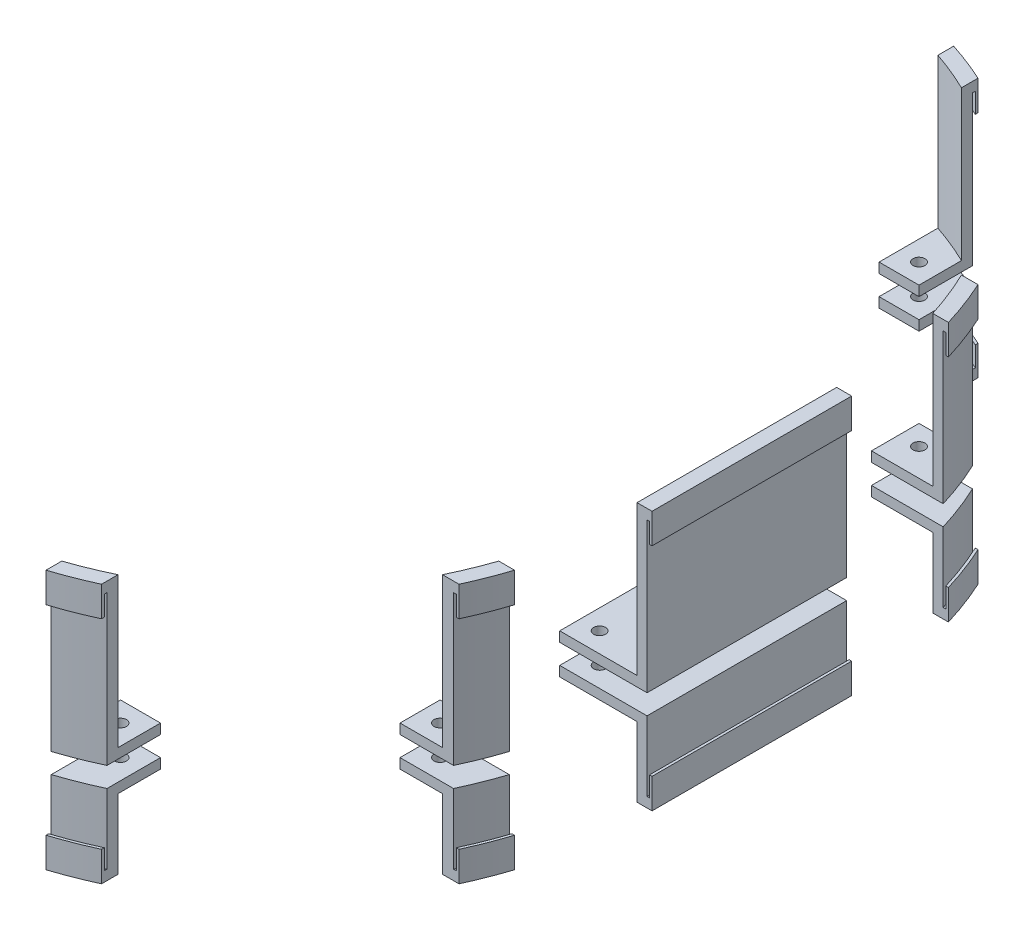
from build123d import *

# Parameters (mm, degrees)
BOSS_EXTRUDE1_DEPTH   = 6.35
CUT_EXTRUDE1_DEPTH    = 6.35
M4_CLEARANCE_HOLE1_D  = 4.5
F_6_CLEARANCE_HOLE1_D = 3.7973
F_6_CLEARANCE_HOLE2_D = 3.7973
SKETCH17_R            = 1.89865
SKETCH17_W            = 27.78125
SKETCH17_H            = 63.5
BOSS_EXTRUDE2_DEPTH   = 3.175
CUT_EXTRUDE4_DEPTH    = 6.35
SKETCH19_W            = 3.175
SKETCH19_H            = 63.5
BOSS_EXTRUDE3_DEPTH   = 44.45
SKETCH22_W            = 3.175
SKETCH22_H            = 63.5
BOSS_EXTRUDE4_DEPTH   = 19.05
SKETCH23_W            = 1.5875
SKETCH23_H            = 63.5
SKETCH23_W_2          = 3.175
BOSS_EXTRUDE5_DEPTH   = 3.175
SKETCH24_W            = 1.5875
SKETCH24_H            = 63.5
SKETCH24_W_2          = 3.175
BOSS_EXTRUDE6_DEPTH   = 3.175
SKETCH25_W            = 0.79375
SKETCH25_H            = 63.5
BOSS_EXTRUDE8_DEPTH   = 6.35
SKETCH27_W            = 0.79375
SKETCH27_H            = 63.5
BOSS_EXTRUDE9_DEPTH   = 6.35


with BuildPart() as part:
    # Sketch1 → Boss-Extrude1 (new body)
    with BuildSketch(Plane(origin=(0, 0, 0), x_dir=(1, 0, 0), z_dir=(0, 1, 0))):
        with BuildLine():
            Line((-34.13125, -148.43125), (34.13125, -148.43125))
            ThreePointArc((34.13125, -148.43125), (114.95355509, -114.95355509), (148.43125, -34.13125))
            Line((148.43125, -34.13125), (148.43125, 34.13125))
            ThreePointArc((148.43125, 34.13125), (114.95355509, 114.95355509), (34.13125, 148.43125))
            Line((34.13125, 148.43125), (-34.13125, 148.43125))
            ThreePointArc((-34.13125, 148.43125), (-114.95355509, 114.95355509), (-148.43125, 34.13125))
            Line((-148.43125, 34.13125), (-148.43125, -34.13125))
            ThreePointArc((-148.43125, -34.13125), (-114.95355509, -114.95355509), (-34.13125, -148.43125))
        make_face()
    extrude(amount=BOSS_EXTRUDE1_DEPTH)

    # Sketch4 → Cut-Extrude1 (cut)
    with BuildSketch(Plane(origin=(0, 6.35, 0), x_dir=(1, 0, 0), z_dir=(0, 1, 0))):
        with BuildLine():
            Line((-39.448, 120.290181937), (39.448, 120.290181937))
            ThreePointArc((39.448, 120.290181937), (49.454528647, 121.702619905), (58.679163809, 125.829568258))
            ThreePointArc((58.679163809, 125.829568258), (62.23, 132.253581937), (58.679163809, 138.677595616))
            ThreePointArc((58.679163809, 138.677595616), (49.454528647, 142.804543969), (39.448, 144.216981937))
            Line((39.448, 144.216981937), (-39.448, 144.216981937))
            ThreePointArc((-39.448, 144.216981937), (-49.454528647, 142.804543969), (-58.679163809, 138.677595616))
            ThreePointArc((-58.679163809, 138.677595616), (-62.23, 132.253581937), (-58.679163809, 125.829568258))
            ThreePointArc((-58.679163809, 125.829568258), (-49.454528647, 121.702619905), (-39.448, 120.290181937))
        make_face()
        with BuildLine():
            ThreePointArc((-39.448, 145.804481937), (-49.893930566, 144.330021666), (-59.523633513, 140.021852723))
            ThreePointArc((-59.523633513, 140.021852723), (-63.8175, 132.253581937), (-59.523633513, 124.485311151))
            ThreePointArc((-59.523633513, 124.485311151), (-49.893930566, 120.177142208), (-39.448, 118.702681937))
            Line((-39.448, 118.702681937), (39.448, 118.702681937))
            ThreePointArc((39.448, 118.702681937), (49.893930566, 120.177142208), (59.523633513, 124.485311151))
            ThreePointArc((59.523633513, 124.485311151), (63.8175, 132.253581937), (59.523633513, 140.021852723))
            ThreePointArc((59.523633513, 140.021852723), (49.893930566, 144.330021666), (39.448, 145.804481937))
            Line((39.448, 145.804481937), (-39.448, 145.804481937))
        make_face()
        with BuildLine():
            ThreePointArc((39.448, 120.290181937), (49.454528647, 121.702619905), (58.679163809, 125.829568258))
            ThreePointArc((58.679163809, 125.829568258), (62.23, 132.253581937), (58.679163809, 138.677595616))
            ThreePointArc((58.679163809, 138.677595616), (49.454528647, 142.804543969), (39.448, 144.216981937))
            Line((39.448, 144.216981937), (-39.448, 144.216981937))
            ThreePointArc((-39.448, 144.216981937), (-49.454528647, 142.804543969), (-58.679163809, 138.677595616))
            ThreePointArc((-58.679163809, 138.677595616), (-62.23, 132.253581937), (-58.679163809, 125.829568258))
            ThreePointArc((-58.679163809, 125.829568258), (-49.454528647, 121.702619905), (-39.448, 120.290181937))
            Line((-39.448, 120.290181937), (39.448, 120.290181937))
        make_face(mode=Mode.SUBTRACT)
        with BuildLine():
            ThreePointArc((-58.679163809, -125.829568258), (-62.23, -132.253581937), (-58.679163809, -138.677595616))
            ThreePointArc((-58.679163809, -138.677595616), (-49.454528647, -142.804543969), (-39.448, -144.216981937))
            Line((-39.448, -144.216981937), (39.448, -144.216981937))
            ThreePointArc((39.448, -144.216981937), (49.454528647, -142.804543969), (58.679163809, -138.677595616))
            ThreePointArc((58.679163809, -138.677595616), (62.23, -132.253581937), (58.679163809, -125.829568258))
            ThreePointArc((58.679163809, -125.829568258), (49.454528647, -121.702619905), (39.448, -120.290181937))
            Line((39.448, -120.290181937), (-39.448, -120.290181937))
            ThreePointArc((-39.448, -120.290181937), (-49.454528647, -121.702619905), (-58.679163809, -125.829568258))
        make_face()
        with BuildLine():
            ThreePointArc((-59.523633513, -124.485311151), (-63.8175, -132.253581937), (-59.523633513, -140.021852723))
            ThreePointArc((-59.523633513, -140.021852723), (-49.893930566, -144.330021666), (-39.448, -145.804481937))
            Line((-39.448, -145.804481937), (39.448, -145.804481937))
            ThreePointArc((39.448, -145.804481937), (49.893930566, -144.330021666), (59.523633513, -140.021852723))
            ThreePointArc((59.523633513, -140.021852723), (63.8175, -132.253581937), (59.523633513, -124.485311151))
            ThreePointArc((59.523633513, -124.485311151), (49.893930566, -120.177142208), (39.448, -118.702681937))
            Line((39.448, -118.702681937), (-39.448, -118.702681937))
            ThreePointArc((-39.448, -118.702681937), (-49.893930566, -120.177142208), (-59.523633513, -124.485311151))
        make_face()
        with BuildLine():
            ThreePointArc((-58.679163809, -138.677595616), (-49.454528647, -142.804543969), (-39.448, -144.216981937))
            Line((-39.448, -144.216981937), (39.448, -144.216981937))
            ThreePointArc((39.448, -144.216981937), (49.454528647, -142.804543969), (58.679163809, -138.677595616))
            ThreePointArc((58.679163809, -138.677595616), (62.23, -132.253581937), (58.679163809, -125.829568258))
            ThreePointArc((58.679163809, -125.829568258), (49.454528647, -121.702619905), (39.448, -120.290181937))
            Line((39.448, -120.290181937), (-39.448, -120.290181937))
            ThreePointArc((-39.448, -120.290181937), (-49.454528647, -121.702619905), (-58.679163809, -125.829568258))
            ThreePointArc((-58.679163809, -125.829568258), (-62.23, -132.253581937), (-58.679163809, -138.677595616))
        make_face(mode=Mode.SUBTRACT)
    extrude(amount=-CUT_EXTRUDE1_DEPTH, mode=Mode.SUBTRACT)

    # M4 Clearance Hole1 (through all)
    with Locations(Plane(origin=(0, 6.35, 0), x_dir=(1, 0, 0), z_dir=(0, 1, 0))):
        with Locations((-16, -103.6875), (16, -103.6875), (22, -60.325), (-10, -60.325), (-10, 60.325), (22, 60.325), (16, 103.6875), (-16, 103.6875)):
            Hole(M4_CLEARANCE_HOLE1_D / 2)

    # #6 Clearance Hole1 (through all)
    with Locations(Plane(origin=(0, 6.35, 0), x_dir=(1, 0, 0), z_dir=(0, 1, 0))):
        with Locations((-101.6, -101.6), (-101.6, 101.6), (101.6, 101.6), (101.6, -101.6), (-127, -76.2), (-127, -50.8), (-127, 50.8), (-127, 76.2), (-101.6, 76.2), (-101.6, 50.8), (-101.6, 25.4), (-101.6, 0), (-101.6, -25.4), (-101.6, -50.8), (-101.6, -76.2), (-76.2, -101.6), (-50.8, -101.6), (-50.8, -76.2), (-76.2, -76.2), (-76.2, -50.8), (-50.8, -50.8), (-50.8, -25.4), (-76.2, -25.4), (-76.2, 0), (-50.8, 0), (-50.8, 25.4), (-76.2, 25.4), (-76.2, 50.8), (-50.8, 50.8), (-50.8, 76.2), (-76.2, 76.2), (-76.2, 101.6), (-50.8, 101.6), (50.8, -101.6), (76.2, -101.6), (101.6, -76.2), (127, -76.2), (127, -50.8), (101.6, -25.4), (101.6, -50.8), (76.2, -25.4), (76.2, -50.8), (76.2, -76.2), (50.8, -76.2), (50.8, -50.8), (50.8, -25.4), (50.8, 0), (76.2, 0), (101.6, 0), (101.6, 25.4), (101.6, 50.8), (101.6, 76.2), (127, 50.8), (127, 76.2), (76.2, 101.6), (50.8, 101.6), (50.8, 76.2), (76.2, 76.2), (76.2, 50.8), (76.2, 25.4), (50.8, 25.4), (50.8, 50.8), (0, 0), (-25.4, -25.4), (-25.4, 0), (-25.4, 25.4), (0, 25.4), (25.4, 25.4), (25.4, 0), (25.4, -25.4), (0, -25.4), (127, -25.4), (127, 0), (127, 25.4), (-127, -25.4), (-127, 0), (-127, 25.4)):
            Hole(F_6_CLEARANCE_HOLE1_D / 2)

    # #6 Clearance Hole2 (through all)
    with Locations(Plane(origin=(0, 6.35, 0), x_dir=(1, 0, 0), z_dir=(0, 1, 0))):
        with Locations((-76.2, -127), (76.2, -127), (76.2, 127), (-76.2, 127)):
            Hole(F_6_CLEARANCE_HOLE2_D / 2)

    # Sketch17 → Boss-Extrude2 (add)
    with BuildSketch(Plane(origin=(0, 6.35, 0), x_dir=(1, 0, 0), z_dir=(0, 1, 0))):
        with BuildLine():
            Line((69.85, -142.706849922), (69.85, -120.65))
            Line((69.85, -120.65), (82.55, -120.65))
            Line((82.55, -120.65), (82.55, -137.6692365))
            ThreePointArc((82.55, -137.6692365), (76.275337531, -140.377971767), (69.85, -142.706849922))
        make_face()
        with Locations((76.2, -127)):
            Circle(SKETCH17_R, mode=Mode.SUBTRACT)
        with BuildLine():
            Line((137.6692365, -82.55), (120.65, -82.55))
            Line((120.65, -82.55), (120.65, -69.85))
            Line((120.65, -69.85), (142.706849922, -69.85))
            ThreePointArc((142.706849922, -69.85), (140.377971767, -76.275337531), (137.6692365, -82.55))
        make_face()
        with Locations((127, -76.2)):
            Circle(SKETCH17_R, mode=Mode.SUBTRACT)
        with Locations((134.540625, 0)):
            Rectangle(SKETCH17_W, SKETCH17_H)
        with Locations((127, -25.4)):
            Circle(SKETCH17_R, mode=Mode.SUBTRACT)
        with Locations((127, 0)):
            Circle(SKETCH17_R, mode=Mode.SUBTRACT)
        with Locations((127, 25.4)):
            Circle(SKETCH17_R, mode=Mode.SUBTRACT)
        with BuildLine():
            Line((143.474597969, 67.425727845), (120.65, 67.425727845))
            Line((120.65, 67.425727845), (120.65, 82.55))
            Line((120.65, 82.55), (137.6692365, 82.55))
            ThreePointArc((137.6692365, 82.55), (140.840207184, 75.090845416), (143.474597969, 67.425727845))
        make_face()
        with Locations((127, 76.2)):
            Circle(SKETCH17_R, mode=Mode.SUBTRACT)
        with BuildLine():
            Line((82.55, 120.65), (82.55, 137.6692365))
            ThreePointArc((82.55, 137.6692365), (76.275337531, 140.377971767), (69.85, 142.706849922))
            Line((69.85, 142.706849922), (69.85, 120.65))
            Line((69.85, 120.65), (82.55, 120.65))
        make_face()
        with Locations((76.2, 127)):
            Circle(SKETCH17_R, mode=Mode.SUBTRACT)
    boss_extrude2 = extrude(amount=BOSS_EXTRUDE2_DEPTH)

    # Mirror3: Boss-Extrude2 across plane
    add(boss_extrude2.mirror(Plane.ZX.offset(3.175)))

    # Sketch18 → Cut-Extrude4 (cut)
    with BuildSketch(Plane.XZ):
        with BuildLine():
            Line((-148.43125, 34.13125), (-148.43125, -34.13125))
            ThreePointArc((-148.43125, -34.13125), (-114.95355509, -114.95355509), (-34.13125, -148.43125))
            Line((-34.13125, -148.43125), (34.13125, -148.43125))
            ThreePointArc((34.13125, -148.43125), (114.95355509, -114.95355509), (148.43125, -34.13125))
            Line((148.43125, -34.13125), (148.43125, 34.13125))
            ThreePointArc((148.43125, 34.13125), (114.95355509, 114.95355509), (34.13125, 148.43125))
            Line((34.13125, 148.43125), (-34.13125, 148.43125))
            ThreePointArc((-34.13125, 148.43125), (-114.95355509, 114.95355509), (-148.43125, 34.13125))
        make_face()
    extrude(amount=-CUT_EXTRUDE4_DEPTH, mode=Mode.SUBTRACT)

    # Sketch19 → Boss-Extrude3 (add)
    with BuildSketch(Plane(origin=(0, 9.525, 0), x_dir=(1, 0, 0), z_dir=(0, 1, 0))):
        with BuildLine():
            Line((82.55, 134.153198958), (82.55, 137.6692365))
            ThreePointArc((82.55, 137.6692365), (76.275337531, 140.377971767), (69.85, 142.706849922))
            Line((69.85, 142.706849922), (69.85, 139.35927157))
            ThreePointArc((69.85, 139.35927157), (76.280455503, 136.952503155), (82.55, 134.153198958))
        make_face()
        with Locations((146.84375, 0)):
            Rectangle(SKETCH19_W, SKETCH19_H)
        with BuildLine():
            Line((140.151264007, 67.425727845), (143.474597969, 67.425727845))
            ThreePointArc((143.474597969, 67.425727845), (140.840207184, 75.090845416), (137.6692365, 82.55))
            Line((137.6692365, 82.55), (134.153198958, 82.55))
            ThreePointArc((134.153198958, 82.55), (137.429403554, 75.097786311), (140.151264007, 67.425727845))
        make_face()
        with BuildLine():
            Line((134.153198958, -82.55), (137.6692365, -82.55))
            ThreePointArc((137.6692365, -82.55), (140.377971767, -76.275337531), (142.706849922, -69.85))
            Line((142.706849922, -69.85), (139.35927157, -69.85))
            ThreePointArc((139.35927157, -69.85), (136.952503155, -76.280455503), (134.153198958, -82.55))
        make_face()
        with BuildLine():
            Line((69.85, -139.35927157), (69.85, -142.706849922))
            ThreePointArc((69.85, -142.706849922), (76.275337531, -140.377971767), (82.55, -137.6692365))
            Line((82.55, -137.6692365), (82.55, -134.153198958))
            ThreePointArc((82.55, -134.153198958), (76.280455503, -136.952503155), (69.85, -139.35927157))
        make_face()
    extrude(amount=BOSS_EXTRUDE3_DEPTH)

    # Sketch22 → Boss-Extrude4 (add)
    with BuildSketch(Plane.XZ.offset(3.175)):
        with BuildLine():
            Line((137.6692365, 82.55), (134.153198958, 82.55))
            ThreePointArc((134.153198958, 82.55), (136.952503155, 76.280455503), (139.35927157, 69.85))
            Line((139.35927157, 69.85), (142.706849922, 69.85))
            ThreePointArc((142.706849922, 69.85), (140.377971767, 76.275337531), (137.6692365, 82.55))
        make_face()
        with BuildLine():
            Line((143.474597969, -67.425727845), (140.151264007, -67.425727845))
            ThreePointArc((140.151264007, -67.425727845), (137.429403554, -75.097786311), (134.153198958, -82.55))
            Line((134.153198958, -82.55), (137.6692365, -82.55))
            ThreePointArc((137.6692365, -82.55), (140.840207184, -75.090845416), (143.474597969, -67.425727845))
        make_face()
        with Locations((146.84375, 0)):
            Rectangle(SKETCH22_W, SKETCH22_H)
        with BuildLine():
            Line((82.55, -137.6692365), (82.55, -134.153198958))
            ThreePointArc((82.55, -134.153198958), (76.280455503, -136.952503155), (69.85, -139.35927157))
            Line((69.85, -139.35927157), (69.85, -142.706849922))
            ThreePointArc((69.85, -142.706849922), (76.275337531, -140.377971767), (82.55, -137.6692365))
        make_face()
        with BuildLine():
            Line((69.85, 142.706849922), (69.85, 139.35927157))
            ThreePointArc((69.85, 139.35927157), (76.280455503, 136.952503155), (82.55, 134.153198958))
            Line((82.55, 134.153198958), (82.55, 137.6692365))
            ThreePointArc((82.55, 137.6692365), (76.275337531, 140.377971767), (69.85, 142.706849922))
        make_face()
    extrude(amount=BOSS_EXTRUDE4_DEPTH)

    # Sketch23 → Boss-Extrude5 (add)
    with BuildSketch(Plane(origin=(0, 53.975, 0), x_dir=(1, 0, 0), z_dir=(0, 1, 0))):
        with BuildLine():
            Line((69.85, -142.706849922), (69.85, -144.376810249))
            ThreePointArc((69.85, -144.376810249), (76.272967802, -142.08488948), (82.55, -139.419128242))
            Line((82.55, -139.419128242), (82.55, -137.6692365))
            ThreePointArc((82.55, -137.6692365), (76.275337531, -140.377971767), (69.85, -142.706849922))
        make_face()
        with BuildLine():
            Line((82.55, -137.6692365), (82.55, -134.153198958))
            ThreePointArc((82.55, -134.153198958), (76.280455503, -136.952503155), (69.85, -139.35927157))
            Line((69.85, -139.35927157), (69.85, -142.706849922))
            ThreePointArc((69.85, -142.706849922), (76.275337531, -140.377971767), (82.55, -137.6692365))
        make_face()
        with BuildLine():
            Line((137.6692365, -82.55), (139.419128242, -82.55))
            ThreePointArc((139.419128242, -82.55), (142.08488948, -76.272967802), (144.376810249, -69.85))
            Line((144.376810249, -69.85), (142.706849922, -69.85))
            ThreePointArc((142.706849922, -69.85), (140.377971767, -76.275337531), (137.6692365, -82.55))
        make_face()
        with BuildLine():
            Line((134.153198958, -82.55), (137.6692365, -82.55))
            ThreePointArc((137.6692365, -82.55), (140.377971767, -76.275337531), (142.706849922, -69.85))
            Line((142.706849922, -69.85), (139.35927157, -69.85))
            ThreePointArc((139.35927157, -69.85), (136.952503155, -76.280455503), (134.153198958, -82.55))
        make_face()
        with Locations((149.225, 0)):
            Rectangle(SKETCH23_W, SKETCH23_H)
        with Locations((146.84375, 0)):
            Rectangle(SKETCH23_W_2, SKETCH23_H)
        with BuildLine():
            Line((143.474597969, 67.425727845), (145.13300855, 67.425727845))
            ThreePointArc((145.13300855, 67.425727845), (142.540141001, 75.087629335), (139.419128242, 82.55))
            Line((139.419128242, 82.55), (137.6692365, 82.55))
            ThreePointArc((137.6692365, 82.55), (140.840207184, 75.090845416), (143.474597969, 67.425727845))
        make_face()
        with BuildLine():
            Line((140.151264007, 67.425727845), (143.474597969, 67.425727845))
            ThreePointArc((143.474597969, 67.425727845), (140.840207184, 75.090845416), (137.6692365, 82.55))
            Line((137.6692365, 82.55), (134.153198958, 82.55))
            ThreePointArc((134.153198958, 82.55), (137.429403554, 75.097786311), (140.151264007, 67.425727845))
        make_face()
        with BuildLine():
            ThreePointArc((82.55, 134.153198958), (76.280455503, 136.952503155), (69.85, 139.35927157))
            Line((69.85, 139.35927157), (69.85, 142.706849922))
            ThreePointArc((69.85, 142.706849922), (76.275337531, 140.377971767), (82.55, 137.6692365))
            Line((82.55, 137.6692365), (82.55, 134.153198958))
        make_face()
        with BuildLine():
            Line((82.55, 137.6692365), (82.55, 139.419128242))
            ThreePointArc((82.55, 139.419128242), (76.272967802, 142.08488948), (69.85, 144.376810249))
            Line((69.85, 144.376810249), (69.85, 142.706849922))
            ThreePointArc((69.85, 142.706849922), (76.275337531, 140.377971767), (82.55, 137.6692365))
        make_face()
    extrude(amount=BOSS_EXTRUDE5_DEPTH)

    # Sketch24 → Boss-Extrude6 (add)
    with BuildSketch(Plane.XZ.offset(22.225)):
        with BuildLine():
            ThreePointArc((142.706849922, 69.85), (140.377971767, 76.275337531), (137.6692365, 82.55))
            Line((137.6692365, 82.55), (139.419128242, 82.55))
            ThreePointArc((139.419128242, 82.55), (142.08488948, 76.272967802), (144.376810249, 69.85))
            Line((144.376810249, 69.85), (142.706849922, 69.85))
        make_face()
        with BuildLine():
            Line((142.706849922, 69.85), (139.35927157, 69.85))
            ThreePointArc((139.35927157, 69.85), (136.952503155, 76.280455503), (134.153198958, 82.55))
            Line((134.153198958, 82.55), (137.6692365, 82.55))
            ThreePointArc((137.6692365, 82.55), (140.377971767, 76.275337531), (142.706849922, 69.85))
        make_face()
        with Locations((149.225, 0)):
            Rectangle(SKETCH24_W, SKETCH24_H)
        with Locations((146.84375, 0)):
            Rectangle(SKETCH24_W_2, SKETCH24_H)
        with BuildLine():
            ThreePointArc((137.6692365, -82.55), (140.840207184, -75.090845416), (143.474597969, -67.425727845))
            Line((143.474597969, -67.425727845), (145.13300855, -67.425727845))
            ThreePointArc((145.13300855, -67.425727845), (142.540141001, -75.087629335), (139.419128242, -82.55))
            Line((139.419128242, -82.55), (137.6692365, -82.55))
        make_face()
        with BuildLine():
            Line((137.6692365, -82.55), (134.153198958, -82.55))
            ThreePointArc((134.153198958, -82.55), (137.429403554, -75.097786311), (140.151264007, -67.425727845))
            Line((140.151264007, -67.425727845), (143.474597969, -67.425727845))
            ThreePointArc((143.474597969, -67.425727845), (140.840207184, -75.090845416), (137.6692365, -82.55))
        make_face()
        with BuildLine():
            ThreePointArc((82.55, 137.6692365), (76.275337531, 140.377971767), (69.85, 142.706849922))
            Line((69.85, 142.706849922), (69.85, 144.376810249))
            ThreePointArc((69.85, 144.376810249), (76.272967802, 142.08488948), (82.55, 139.419128242))
            Line((82.55, 139.419128242), (82.55, 137.6692365))
        make_face()
        with BuildLine():
            Line((82.55, 137.6692365), (82.55, 134.153198958))
            ThreePointArc((82.55, 134.153198958), (76.280455503, 136.952503155), (69.85, 139.35927157))
            Line((69.85, 139.35927157), (69.85, 142.706849922))
            ThreePointArc((69.85, 142.706849922), (76.275337531, 140.377971767), (82.55, 137.6692365))
        make_face()
        with BuildLine():
            Line((69.85, -142.706849922), (69.85, -139.35927157))
            ThreePointArc((69.85, -139.35927157), (76.280455503, -136.952503155), (82.55, -134.153198958))
            Line((82.55, -134.153198958), (82.55, -137.6692365))
            ThreePointArc((82.55, -137.6692365), (76.275337531, -140.377971767), (69.85, -142.706849922))
        make_face()
        with BuildLine():
            ThreePointArc((69.85, -142.706849922), (76.275337531, -140.377971767), (82.55, -137.6692365))
            Line((82.55, -137.6692365), (82.55, -139.419128242))
            ThreePointArc((82.55, -139.419128242), (76.272967802, -142.08488948), (69.85, -144.376810249))
            Line((69.85, -144.376810249), (69.85, -142.706849922))
        make_face()
    extrude(amount=BOSS_EXTRUDE6_DEPTH)

    # Sketch25 → Boss-Extrude8 (add)
    with BuildSketch(Plane.XZ.offset(-53.975)):
        with BuildLine():
            ThreePointArc((69.85, -144.376810249), (76.272967802, -142.08488948), (82.55, -139.419128242))
            Line((82.55, -139.419128242), (82.55, -138.544831193))
            ThreePointArc((82.55, -138.544831193), (76.274137808, -141.231895639), (69.85, -143.54213697))
            Line((69.85, -143.54213697), (69.85, -144.376810249))
        make_face()
        with BuildLine():
            ThreePointArc((144.304064406, -67.425727845), (141.690611266, -75.089217394), (138.544831193, -82.55))
            Line((138.544831193, -82.55), (139.419128242, -82.55))
            ThreePointArc((139.419128242, -82.55), (142.540141001, -75.087629335), (145.13300855, -67.425727845))
            Line((145.13300855, -67.425727845), (144.304064406, -67.425727845))
        make_face()
        with Locations((149.621875, 0)):
            Rectangle(SKETCH25_W, SKETCH25_H)
        with BuildLine():
            Line((139.419128242, 82.55), (138.544831193, 82.55))
            ThreePointArc((138.544831193, 82.55), (141.231895639, 76.274137808), (143.54213697, 69.85))
            Line((143.54213697, 69.85), (144.376810249, 69.85))
            ThreePointArc((144.376810249, 69.85), (142.08488948, 76.272967802), (139.419128242, 82.55))
        make_face()
        with BuildLine():
            Line((69.85, 144.376810249), (69.85, 143.54213697))
            ThreePointArc((69.85, 143.54213697), (76.274137808, 141.231895639), (82.55, 138.544831193))
            Line((82.55, 138.544831193), (82.55, 139.419128242))
            ThreePointArc((82.55, 139.419128242), (76.272967802, 142.08488948), (69.85, 144.376810249))
        make_face()
    extrude(amount=BOSS_EXTRUDE8_DEPTH)

    # Sketch27 → Boss-Extrude9 (add)
    with BuildSketch(Plane(origin=(0, -22.225, 0), x_dir=(1, 0, 0), z_dir=(0, 1, 0))):
        with BuildLine():
            Line((69.85, 143.54213697), (69.85, 144.376810249))
            ThreePointArc((69.85, 144.376810249), (76.272967802, 142.08488948), (82.55, 139.419128242))
            Line((82.55, 139.419128242), (82.55, 138.544831193))
            ThreePointArc((82.55, 138.544831193), (76.274137808, 141.231895639), (69.85, 143.54213697))
        make_face()
        with BuildLine():
            Line((138.544831193, 82.55), (139.419128242, 82.55))
            ThreePointArc((139.419128242, 82.55), (142.540141001, 75.087629335), (145.13300855, 67.425727845))
            Line((145.13300855, 67.425727845), (144.304064406, 67.425727845))
            ThreePointArc((144.304064406, 67.425727845), (141.690611266, 75.089217394), (138.544831193, 82.55))
        make_face()
        with Locations((149.621875, 0)):
            Rectangle(SKETCH27_W, SKETCH27_H)
        with BuildLine():
            Line((143.54213697, -69.85), (144.376810249, -69.85))
            ThreePointArc((144.376810249, -69.85), (142.08488948, -76.272967802), (139.419128242, -82.55))
            Line((139.419128242, -82.55), (138.544831193, -82.55))
            ThreePointArc((138.544831193, -82.55), (141.231895639, -76.274137808), (143.54213697, -69.85))
        make_face()
        with BuildLine():
            Line((82.55, -138.544831193), (82.55, -139.419128242))
            ThreePointArc((82.55, -139.419128242), (76.272967802, -142.08488948), (69.85, -144.376810249))
            Line((69.85, -144.376810249), (69.85, -143.54213697))
            ThreePointArc((69.85, -143.54213697), (76.274137808, -141.231895639), (82.55, -138.544831193))
        make_face()
    extrude(amount=BOSS_EXTRUDE9_DEPTH)


solid = part.part
